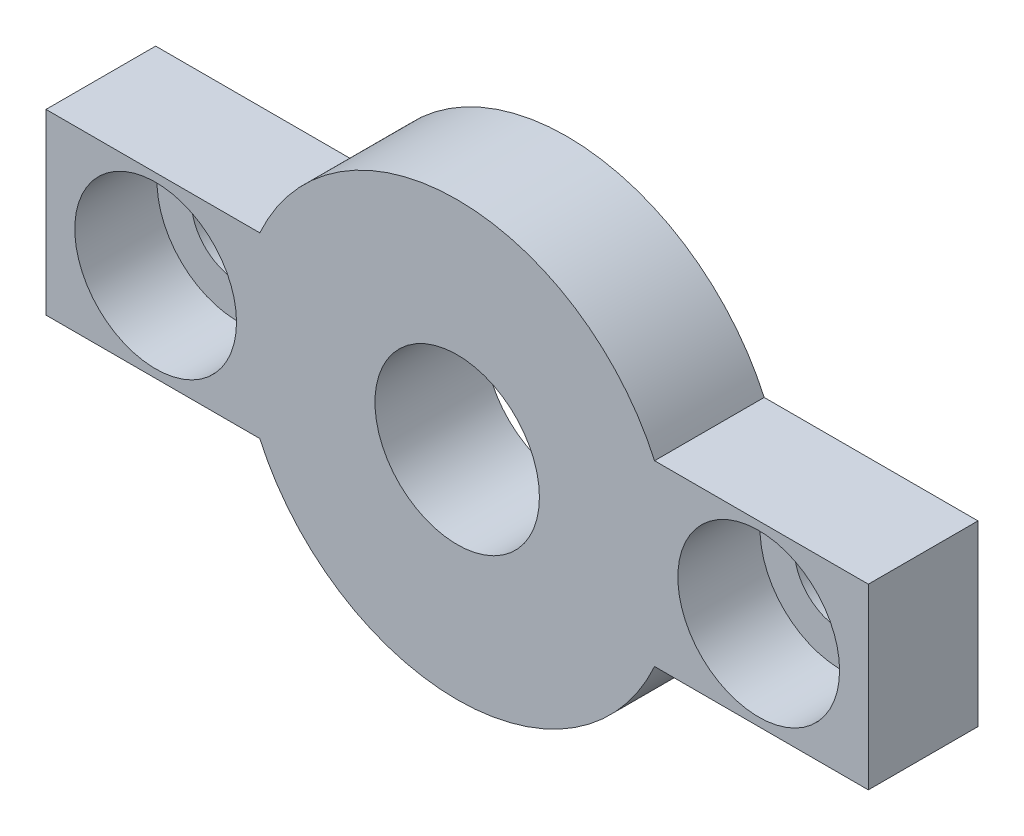
from build123d import *

# Parameters (mm, degrees)
CROQUIS1_R              = 3
SALIENTE_EXTRUIR1_DEPTH = 4
CROQUIS2_R              = 1.7
CORTAR_EXTRUIR1_DEPTH   = 4
CROQUIS3_R              = 2.95
CORTAR_EXTRUIR2_DEPTH   = 3


with BuildPart() as part:
    # Croquis1 → Saliente-Extruir1 (new body)
    with BuildSketch(Plane.XY):
        with BuildLine():
            Line((-7.200520814, 3.25), (-15, 3.25))
            Line((-15, 3.25), (-15, -3.25))
            Line((-15, -3.25), (-7.200520814, -3.25))
            ThreePointArc((-7.200520814, -3.25), (0, -7.9), (7.200520814, -3.25))
            Line((7.200520814, -3.25), (15, -3.25))
            Line((15, -3.25), (15, 3.25))
            Line((15, 3.25), (7.200520814, 3.25))
            ThreePointArc((7.200520814, 3.25), (0, 7.9), (-7.200520814, 3.25))
        make_face()
        Circle(CROQUIS1_R, mode=Mode.SUBTRACT)
    extrude(amount=SALIENTE_EXTRUIR1_DEPTH)

    # Croquis2 → Cortar-Extruir1 (cut)
    with BuildSketch(Plane.XY.offset(4)):
        with Locations((-11, 0)):
            Circle(CROQUIS2_R)
        with Locations((11, 0)):
            Circle(CROQUIS2_R)
    extrude(amount=-CORTAR_EXTRUIR1_DEPTH, mode=Mode.SUBTRACT)

    # Croquis3 → Cortar-Extruir2 (cut)
    with BuildSketch(Plane.XY.offset(4)):
        with Locations((-11, 0)):
            Circle(CROQUIS3_R)
        with Locations((11, 0)):
            Circle(CROQUIS3_R)
    extrude(amount=-CORTAR_EXTRUIR2_DEPTH, mode=Mode.SUBTRACT)


solid = part.part
